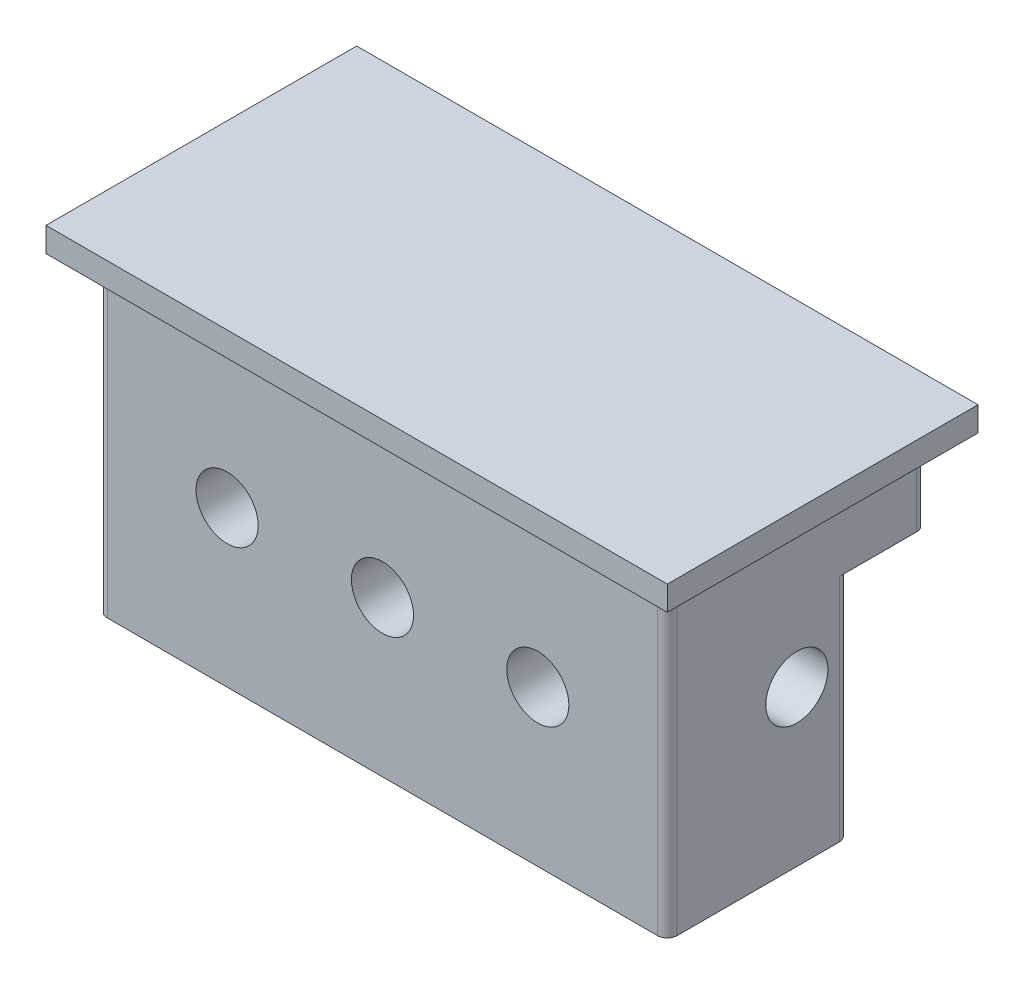
from build123d import *

# Parameters (mm, degrees)
SKETCH2_W           = 50.8
SKETCH2_H           = 25.4
BOSS_EXTRUDE2_DEPTH = 1.999996
SKETCH2_4_W         = 46.5836
SKETCH2_4_H         = 21.1836
BOSS_EXTRUDE3_DEPTH = 25.4
FILLET3_R           = 0.79375
SKETCH3_R           = 2.54
CUT_EXTRUDE1_DEPTH  = 61.507944827
SKETCH4_R           = 2.54
CUT_EXTRUDE2_DEPTH  = 62.386545327
SKETCH5_W           = 46.5836
SKETCH5_H           = 18.796
CUT_EXTRUDE3_DEPTH  = 6.35
FILLET4_R           = 0.762


with BuildPart() as part:
    # Sketch2 → Boss-Extrude2 (new body)
    with BuildSketch(Plane(origin=(0, 0, 0), x_dir=(1, 0, 0), z_dir=(0, 1, 0))):
        with Locations((25.4, 12.7)):
            Rectangle(SKETCH2_W, SKETCH2_H)
    extrude(amount=BOSS_EXTRUDE2_DEPTH)

    # Sketch2_4 → Boss-Extrude3 (add)
    with BuildSketch(Plane(origin=(0, 0, 0), x_dir=(1, 0, 0), z_dir=(0, 1, 0))):
        with Locations((25.4, 12.7)):
            Rectangle(SKETCH2_4_W, SKETCH2_4_H)
    extrude(amount=-BOSS_EXTRUDE3_DEPTH)

    # Fillet3
    fillet3_edges = [part.edges().sort_by_distance(p)[0] for p in [
        (2.1082, -12.7, -23.2918),
        (48.6918, -12.7, -2.1082),
        (2.1082, -12.7, -2.1082),
        (48.6918, -12.7, -23.2918),
    ]]
    fillet(fillet3_edges, radius=FILLET3_R)

    # Sketch3 → Cut-Extrude1 (cut, through all)
    with BuildSketch(Plane(origin=(48.6918, 0, 0), x_dir=(0, 0, -1), z_dir=(1, 0, 0))):
        with Locations((12.7, -12.7)):
            Circle(SKETCH3_R)
    extrude(amount=-CUT_EXTRUDE1_DEPTH, mode=Mode.SUBTRACT)

    # Sketch4 → Cut-Extrude2 (cut, through all)
    with BuildSketch(Plane(origin=(0, 0, -23.2918), x_dir=(-1, 0, 0), z_dir=(0, 0, -1))):
        with Locations((-25.4, -12.7)):
            Circle(SKETCH4_R)
        with Locations((-38.1, -12.7)):
            Circle(SKETCH4_R)
        with Locations((-12.7, -12.7)):
            Circle(SKETCH4_R)
    extrude(amount=-CUT_EXTRUDE2_DEPTH, mode=Mode.SUBTRACT)

    # Sketch5 → Cut-Extrude3 (cut)
    with BuildSketch(Plane(origin=(0, 0, -23.2918), x_dir=(-1, 0, 0), z_dir=(0, 0, -1))):
        with Locations((-25.4, -16.002)):
            Rectangle(SKETCH5_W, SKETCH5_H)
    extrude(amount=-CUT_EXTRUDE3_DEPTH, mode=Mode.SUBTRACT)

    # Fillet4
    fillet4_edges = [part.edges().sort_by_distance(p)[0] for p in [
        (48.6918, -16.002, -16.9418),
        (2.1082, -16.002, -16.9418),
    ]]
    fillet(fillet4_edges, radius=FILLET4_R)


solid = part.part
